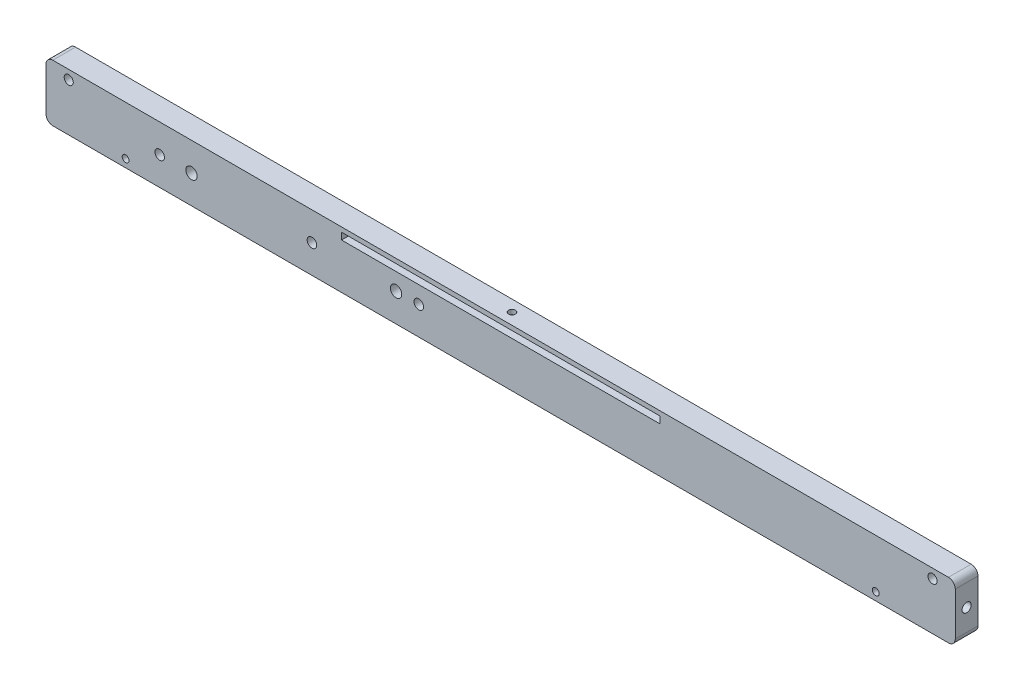
from build123d import *

# Parameters (mm, degrees)
EXTRUDE_1_DEPTH        = 10
SKETCH_3_W             = 140
SKETCH_3_H             = 3
CUT_EXTRUDE_1_DEPTH    = 10
CUT_EXTRUDE_2_DEPTH    = 10
HOLE_WIZARD_M5_3_D     = 4.2
HOLE_WIZARD_M5_3_DEPTH = 14
HOLE_WIZARD_M5_3_TIP   = 1.2618073
HOLE_WIZARD_M6_2_D     = 5
HOLE_WIZARD_M6_2_DEPTH = 17
HOLE_WIZARD_M6_2_TIP   = 1.502151548
SKETCH_10_W            = 15
SKETCH_10_H            = 2.5
CUT_EXTRUDE_3_DEPTH    = 7
SKETCH_11_R            = 1.5
CUT_EXTRUDE_4_DEPTH    = 11
SKETCH_13_R            = 2
CUT_EXTRUDE_6_DEPTH    = 5
SKETCH_14_R            = 2
CUT_EXTRUDE_7_DEPTH    = 5
SKETCH_16_R            = 1.5
CUT_EXTRUDE_8_DEPTH    = 10


with BuildPart() as part:
    # 草图1 → 凸台-拉伸1 (new body)
    with BuildSketch(Plane.XY):
        with BuildLine():
            Line((-197, 12.5), (197, 12.5))
            ThreePointArc((197, 12.5), (199.121320344, 11.621320344), (200, 9.5))
            Line((200, 9.5), (200, -9.5))
            ThreePointArc((200, -9.5), (199.121320344, -11.621320344), (197, -12.5))
            Line((197, -12.5), (-197, -12.5))
            ThreePointArc((-197, -12.5), (-199.121320344, -11.621320344), (-200, -9.5))
            Line((-200, -9.5), (-200, 9.5))
            ThreePointArc((-200, 9.5), (-199.121320344, 11.621320344), (-197, 12.5))
        make_face()
    extrude(amount=-EXTRUDE_1_DEPTH)

    # 草图3 → 切除-拉伸1 (cut)
    with BuildSketch(Plane.XY):
        with Locations((0, 9)):
            Rectangle(SKETCH_3_W, SKETCH_3_H)
    extrude(amount=-CUT_EXTRUDE_1_DEPTH, mode=Mode.SUBTRACT)

    # 草图4 → 切除-拉伸2 (cut)
    with BuildSketch(Plane.XY):
        with BuildLine():
            ThreePointArc((-190, 10.5), (-191.414213562, 9.914213562), (-192, 8.5))
            Line((-192, 8.5), (-190, 8.5))
            Line((-190, 8.5), (-190, 10.5))
        make_face()
        with BuildLine():
            Line((-190, 8.5), (-192, 8.5))
            ThreePointArc((-192, 8.5), (-191.414213562, 7.085786438), (-190, 6.5))
            Line((-190, 6.5), (-190, 8.5))
        make_face()
        with BuildLine():
            Line((-190, 10.5), (-190, 8.5))
            Line((-190, 8.5), (-188, 8.5))
            ThreePointArc((-188, 8.5), (-188.585786438, 9.914213562), (-190, 10.5))
        make_face()
        with BuildLine():
            Line((-188, 8.5), (-190, 8.5))
            Line((-190, 8.5), (-190, 6.5))
            ThreePointArc((-190, 6.5), (-188.585786438, 7.085786438), (-188, 8.5))
        make_face()
        with BuildLine():
            ThreePointArc((190, 10.5), (188.585786438, 9.914213562), (188, 8.5))
            Line((188, 8.5), (190, 8.5))
            Line((190, 8.5), (190, 10.5))
        make_face()
        with BuildLine():
            Line((190, 8.5), (188, 8.5))
            ThreePointArc((188, 8.5), (188.585786438, 7.085786438), (190, 6.5))
            Line((190, 6.5), (190, 8.5))
        make_face()
        with BuildLine():
            Line((190, 10.5), (190, 8.5))
            Line((190, 8.5), (192, 8.5))
            ThreePointArc((192, 8.5), (191.414213562, 9.914213562), (190, 10.5))
        make_face()
        with BuildLine():
            Line((192, 8.5), (190, 8.5))
            Line((190, 8.5), (190, 6.5))
            ThreePointArc((190, 6.5), (191.414213562, 7.085786438), (192, 8.5))
        make_face()
    extrude(amount=-CUT_EXTRUDE_2_DEPTH, mode=Mode.SUBTRACT)

    # M5 螺纹孔3
    with Locations(Plane.XY):
        with Locations((-150, 0), (-83, 0), (-36, 0)):
            Hole(HOLE_WIZARD_M5_3_D / 2, depth=HOLE_WIZARD_M5_3_DEPTH)
            with Locations((0, 0, -(HOLE_WIZARD_M5_3_DEPTH + HOLE_WIZARD_M5_3_TIP / 2))):  # 118° drill point
                Cone(0, HOLE_WIZARD_M5_3_D / 2, HOLE_WIZARD_M5_3_TIP, mode=Mode.SUBTRACT)

    # M6 螺纹孔2
    with Locations(Plane.XY):
        with Locations((-46, 0), (-136, 0)):
            Hole(HOLE_WIZARD_M6_2_D / 2, depth=HOLE_WIZARD_M6_2_DEPTH)
            with Locations((0, 0, -(HOLE_WIZARD_M6_2_DEPTH + HOLE_WIZARD_M6_2_TIP / 2))):  # 118° drill point
                Cone(0, HOLE_WIZARD_M6_2_D / 2, HOLE_WIZARD_M6_2_TIP, mode=Mode.SUBTRACT)

    # 草图10 → 切除-拉伸3 (cut)
    with BuildSketch(Plane.XZ.offset(12.5)):
        with Locations((-172.5, -3.75)):
            Rectangle(SKETCH_10_W, SKETCH_10_H)
        with Locations((-157.5, -3.75)):
            Rectangle(SKETCH_10_W, SKETCH_10_H)
        with Locations((-157.5, -6.25)):
            Rectangle(SKETCH_10_W, SKETCH_10_H)
        with Locations((-172.5, -6.25)):
            Rectangle(SKETCH_10_W, SKETCH_10_H)
        with Locations((157.5, -3.75)):
            Rectangle(SKETCH_10_W, SKETCH_10_H)
        with Locations((172.5, -3.75)):
            Rectangle(SKETCH_10_W, SKETCH_10_H)
        with Locations((157.5, -6.25)):
            Rectangle(SKETCH_10_W, SKETCH_10_H)
        with Locations((172.5, -6.25)):
            Rectangle(SKETCH_10_W, SKETCH_10_H)
    extrude(amount=-CUT_EXTRUDE_3_DEPTH, mode=Mode.SUBTRACT)

    # 草图11 → 切除-拉伸4 (cut, through all)
    with BuildSketch(Plane.XY):
        with Locations((-165, -9)):
            Circle(SKETCH_11_R)
        with Locations((165.001644556, -9)):
            Circle(SKETCH_11_R)
    extrude(amount=-CUT_EXTRUDE_4_DEPTH, mode=Mode.SUBTRACT)

    # 草图13 → 切除-拉伸6 (cut)
    with BuildSketch(Plane(origin=(200, 0, 0), x_dir=(0, 0, -1), z_dir=(1, 0, 0))):
        with Locations((5, 0)):
            Circle(SKETCH_13_R)
    extrude(amount=-CUT_EXTRUDE_6_DEPTH, mode=Mode.SUBTRACT)

    # 草图14 → 切除-拉伸7 (cut)
    with BuildSketch(Plane.ZY.offset(200)):
        with Locations((-5, 0)):
            Circle(SKETCH_14_R)
    extrude(amount=-CUT_EXTRUDE_7_DEPTH, mode=Mode.SUBTRACT)

    # 草图16 → 切除-拉伸8 (cut)
    with BuildSketch(Plane(origin=(0, 12.5, 0), x_dir=(1, 0, 0), z_dir=(0, 1, 0))):
        with Locations((0, 5)):
            Circle(SKETCH_16_R)
    extrude(amount=-CUT_EXTRUDE_8_DEPTH, mode=Mode.SUBTRACT)


solid = part.part
